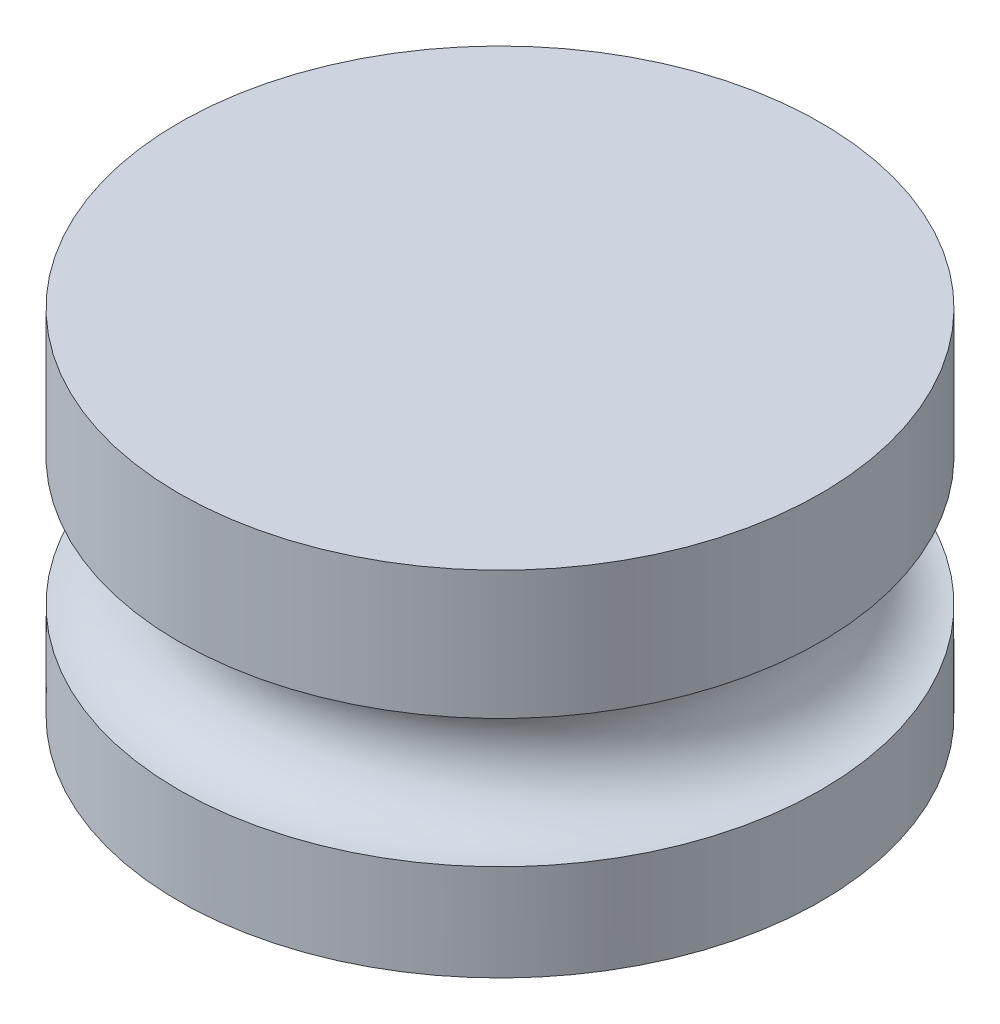
from build123d import *

# Parameters (mm, degrees)
SKETCH1_R            = 5
SKETCH1_R_2          = 1
BOSS_EXTRUDE1_DEPTH  = 4
CUT_SWEEP1_PROFILE_R = 1
SKETCH13_R           = 5
BOSS_EXTRUDE2_DEPTH  = 1
SKETCH14_R           = 5
SKETCH14_R_2         = 1
BOSS_EXTRUDE3_DEPTH  = 0.5


with BuildPart() as part:
    # Sketch1 → Boss-Extrude1 (new body)
    with BuildSketch(Plane(origin=(0, 0, 0), x_dir=(1, 0, 0), z_dir=(0, 1, 0))):
        with Locations(Location((0, 0, 0), (0, 0, 270))):
            Circle(SKETCH1_R)
        with Locations(Location((0, 0, 0), (0, 0, 270))):
            Circle(SKETCH1_R_2, mode=Mode.SUBTRACT)
    extrude(amount=BOSS_EXTRUDE1_DEPTH)

    # Cut-Sweep1: sweep along a path in Sketch2
    with BuildLine(Plane(origin=(0, 2, 0), x_dir=(1, 0, 0), z_dir=(0, 1, 0))) as cut_sweep1_path:
        CenterArc((0, 0), 5, 0, 360)
    # Cut-Sweep1 profile (on start of the path) → Cut-Sweep1 (sweep, cut)
    with BuildSketch(Plane(origin=(5, 2, 0), x_dir=(-1, 0, 0), z_dir=(0, 0, -1))):
        Circle(CUT_SWEEP1_PROFILE_R)
    sweep(path=cut_sweep1_path.line, mode=Mode.SUBTRACT)

    # Sketch13 → Boss-Extrude2 (add)
    with BuildSketch(Plane(origin=(0, 4, 0), x_dir=(1, 0, 0), z_dir=(0, 1, 0))):
        with Locations(Location((0, 0, 0), (0, 0, 270))):
            Circle(SKETCH13_R)
    extrude(amount=BOSS_EXTRUDE2_DEPTH)

    # Sketch14 → Boss-Extrude3 (add)
    with BuildSketch(Plane.XZ):
        with Locations(Location((0, 0, 0), (0, 0, 90))):
            Circle(SKETCH14_R)
        with Locations(Location((0, 0, 0), (0, 0, 270))):
            Circle(SKETCH14_R_2, mode=Mode.SUBTRACT)
    extrude(amount=BOSS_EXTRUDE3_DEPTH)


solid = part.part
